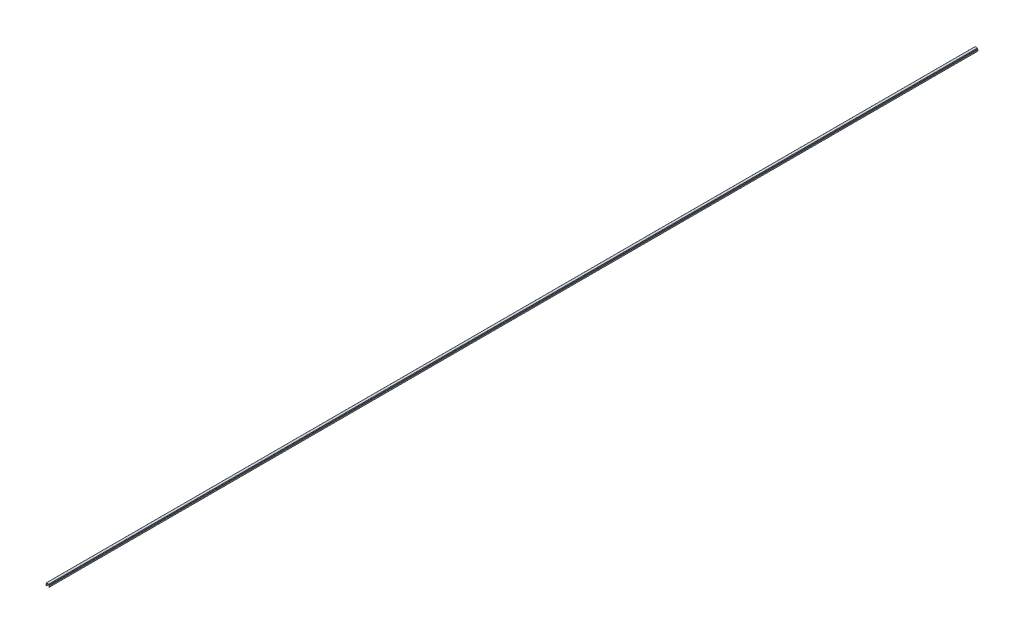
from build123d import *

# Parameters (mm, degrees)
BOSS_EXTRUDE1_DEPTH      = 1000
BOSS_EXTRUDE1_DEPTH_BACK = 1000


with BuildPart() as part:
    # Sketch1 → Boss-Extrude1 (new, two sides: drawn at the far end of the back side and taken through both)
    with BuildSketch(Plane.XY.offset(-BOSS_EXTRUDE1_DEPTH_BACK)):
        with BuildLine():
            Line((-3.6, 3.35), (-3, 0))
            Line((-3, 0), (-2.2, 0))
            Line((-2.2, 0), (-2.735217071, 2.988295315))
            ThreePointArc((-2.735217071, 2.988295315), (-2.659117427, 3.274614514), (-2.390699246, 3.4))
            Line((-2.390699246, 3.4), (-2.2, 3.4))
            Line((-2.2, 3.4), (-2.070472639, 4.88050451))
            ThreePointArc((-2.070472639, 4.88050451), (-1.958261067, 5.108047068), (-1.721804495, 5.2))
            Line((-1.721804495, 5.2), (1.721804495, 5.2))
            ThreePointArc((1.721804495, 5.2), (1.958261067, 5.108047068), (2.070472639, 4.88050451))
            Line((2.070472639, 4.88050451), (2.2, 3.4))
            Line((2.2, 3.4), (2.390699246, 3.4))
            ThreePointArc((2.390699246, 3.4), (2.659117427, 3.274614514), (2.735217071, 2.988295315))
            Line((2.735217071, 2.988295315), (2.2, 0))
            Line((2.2, 0), (3, 0))
            Line((3, 0), (3.6, 3.35))
            ThreePointArc((3.6, 3.35), (3.497487373, 3.597487373), (3.25, 3.7))
            Line((3.25, 3.7), (3, 3.7))
            Line((3, 3.7), (2.835477174, 5.58050451))
            ThreePointArc((2.835477174, 5.58050451), (2.723265602, 5.808047068), (2.486809029, 5.9))
            Line((2.486809029, 5.9), (-2.486809029, 5.9))
            ThreePointArc((-2.486809029, 5.9), (-2.723265602, 5.808047068), (-2.835477174, 5.58050451))
            Line((-2.835477174, 5.58050451), (-3, 3.7))
            Line((-3, 3.7), (-3.25, 3.7))
            ThreePointArc((-3.25, 3.7), (-3.497487373, 3.597487373), (-3.6, 3.35))
        make_face()
    extrude(amount=BOSS_EXTRUDE1_DEPTH + BOSS_EXTRUDE1_DEPTH_BACK)


solid = part.part
